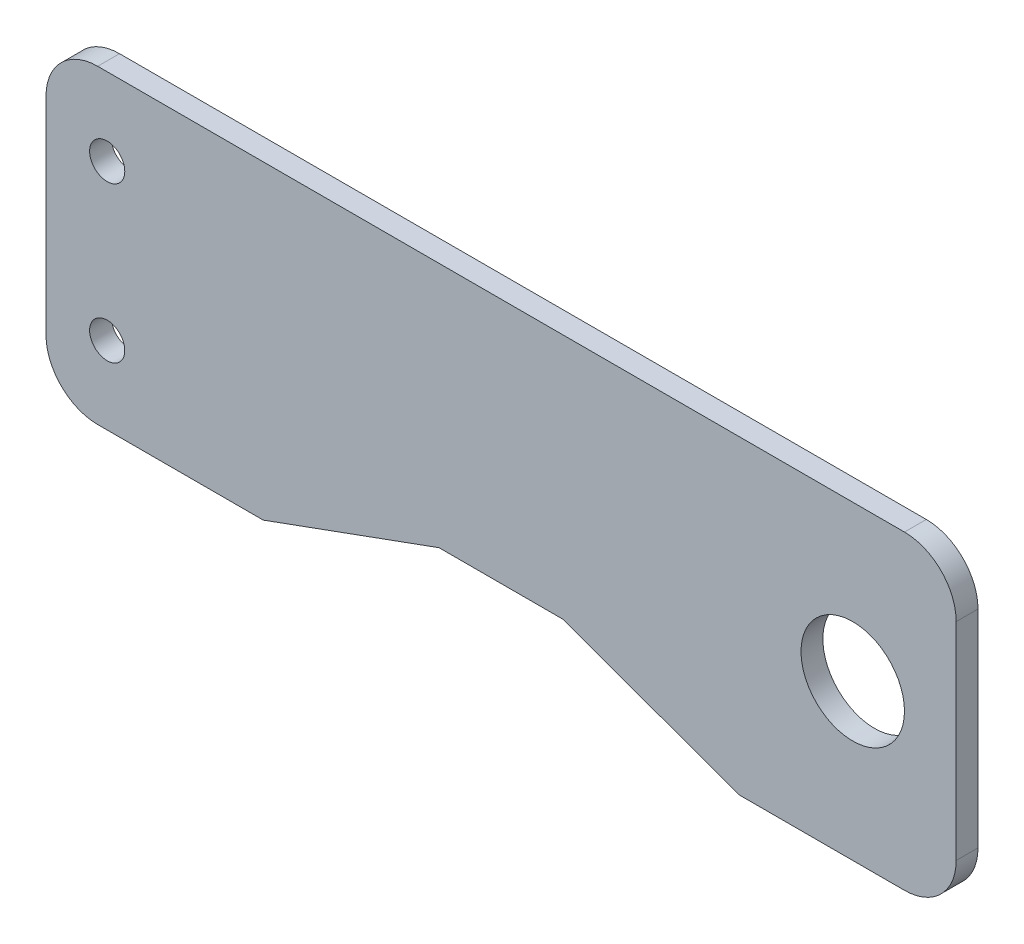
from build123d import *

# Parameters (mm, degrees)
CROQUIS1_W              = 88
CROQUIS1_H              = 30
CROQUIS1_R              = 1.7
SALIENTE_EXTRUIR1_DEPTH = 2.11
CROQUIS6_R              = 5
CORTAR_EXTRUIR2_DEPTH   = 2.11
CORTAR_EXTRUIR3_DEPTH   = 2.11
REDONDEO1_R             = 5


with BuildPart() as part:
    # Croquis1 → Saliente-Extruir1 (new body)
    with BuildSketch(Plane.XY):
        with Locations((36.708826457, -6.405767977)):
            Rectangle(CROQUIS1_W, CROQUIS1_H)
        with Locations((-1.37457934, 1.094232023)):
            Circle(CROQUIS1_R, mode=Mode.SUBTRACT)
        with Locations((-1.37457934, -13.905767977)):
            Circle(CROQUIS1_R, mode=Mode.SUBTRACT)
    extrude(amount=SALIENTE_EXTRUIR1_DEPTH)

    # Croquis6 → Cortar-Extruir2 (cut)
    with BuildSketch(Plane.XY.offset(2.11)):
        with Locations((70.708826457, -6.405767977)):
            Circle(CROQUIS6_R)
    extrude(amount=-CORTAR_EXTRUIR2_DEPTH, mode=Mode.SUBTRACT)

    # Croquis7 → Cortar-Extruir3 (cut)
    with BuildSketch(Plane.XY.offset(2.11)):
        Polygon((13.708826457, -21.405767977), (30.708826457, -15.218273994), (42.708826457, -15.218273994), (59.708826457, -21.405767977), align=None)
    extrude(amount=-CORTAR_EXTRUIR3_DEPTH, mode=Mode.SUBTRACT)

    # Redondeo1
    redondeo1_edges = [part.edges().sort_by_distance(p)[0] for p in [
        (80.708826457, 8.594232023, 1.055),
        (80.708826457, -21.405767977, 1.055),
        (-7.291173543, -21.405767977, 1.055),
        (-7.291173543, 8.594232023, 1.055),
    ]]
    fillet(redondeo1_edges, radius=REDONDEO1_R)


solid = part.part
